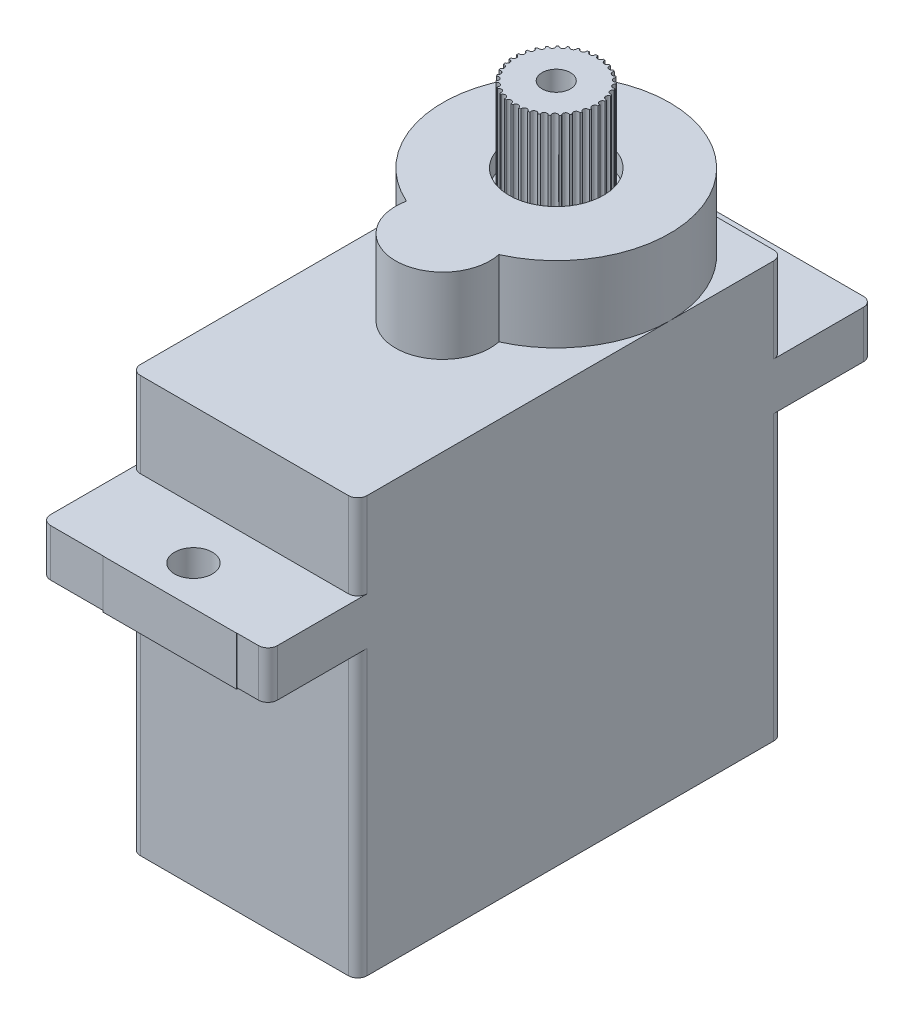
from build123d import *

# Parameters (mm, degrees)
Y_KSEKLIK_EKSTR_ZYON1_DEPTH  = 1
Y_KSEKLIK_EKSTR_ZYON2_DEPTH  = 5
IZIM3_W                      = 4
IZIM3_H                      = 1
KES_EKSTR_ZYON1_DEPTH        = 1
RADYUS1_R                    = 0.1
Y_KSEKLIK_EKSTR_ZYON4_DEPTH  = 9
Y_KSEKLIK_EKSTR_ZYON5_DEPTH  = 2.5
Y_KSEKLIK_EKSTR_ZYON6_DEPTH  = 3.5
Y_KSEKLIK_EKSTR_ZYON7_DEPTH  = 1
KES_EKSTR_ZYON2_DEPTH        = 1
Y_KSEKLIK_EKSTR_ZYON8_START  = 3
Y_KSEKLIK_EKSTR_ZYON8_DEPTH  = 3
RADYUS2_R                    = 0.5
Y_KSEKLIK_EKSTR_ZYON9_START  = 1
Y_KSEKLIK_EKSTR_ZYON9_DEPTH  = 1
IZIM11_R                     = 2.5
KES_EKSTR_ZYON3_DEPTH        = 10
IZIM15_R                     = 0.25
Y_KSEKLIK_EKSTR_ZYON12_DEPTH = 11
IZIM19_R                     = 2.25
Y_KSEKLIK_EKSTR_ZYON17_DEPTH = 5
IZIM20_R                     = 4.75
Y_KSEKLIK_EKSTR_ZYON18_DEPTH = 3
IZIM21_R                     = 0.75
KES_EKSTR_ZYON5_DEPTH        = 10
IZIM22_R                     = 0.5
Y_KSEKLIK_EKSTR_ZYON19_DEPTH = 5
IZIM23_R                     = 4
Y_KSEKLIK_EKSTR_ZYON20_DEPTH = 2
IZIM24_R                     = 0.75
Y_KSEKLIK_EKSTR_ZYON21_DEPTH = 7
IZIM25_R                     = 3.5
Y_KSEKLIK_EKSTR_ZYON22_DEPTH = 1
IZIM26_R                     = 4.5
Y_KSEKLIK_EKSTR_ZYON23_DEPTH = 1
KES_EKSTR_ZYON7_DEPTH        = 30
Y_KSEKLIK_EKSTR_ZYON33_DEPTH = 1
Y_KSEKLIK_EKSTR_ZYON34_DEPTH = 14
IZIM37_W                     = 8
IZIM37_H                     = 6
Y_KSEKLIK_EKSTR_ZYON36_DEPTH = 1
IZIM39_W                     = 4
IZIM39_H                     = 1
Y_KSEKLIK_EKSTR_ZYON37_DEPTH = 0.1
IZIM40_R                     = 0.4
Y_KSEKLIK_EKSTR_ZYON38_DEPTH = 2
IZIM41_R                     = 0.15
KES_EKSTR_ZYON8_DEPTH        = 5
SKETCH4_W                    = 7.062271717
SKETCH4_H                    = 4.39837951
BOSS_EXTRUDE6_DEPTH          = 2.57
SKETCH5_W                    = 6.419494601
SKETCH5_H                    = 4.235737176
BOSS_EXTRUDE7_DEPTH          = 2.57
SKETCH6_R                    = 1
CUT_EXTRUDE1_DEPTH           = 12.57


with BuildPart() as part:
    # Çizim1 → Yükseklik-Ekstrüzyon1 (new body)
    with BuildSketch(Plane(origin=(0, 0, 0), x_dir=(1, 0, 0), z_dir=(0, 1, 0))):
        with BuildLine():
            Line((-5.5, 11.25), (5.5, 11.25))
            ThreePointArc((5.5, 11.25), (5.853553391, 11.103553391), (6, 10.75))
            Line((6, 10.75), (6, -10.75))
            ThreePointArc((6, -10.75), (5.853553391, -11.103553391), (5.5, -11.25))
            Line((5.5, -11.25), (-5.5, -11.25))
            ThreePointArc((-5.5, -11.25), (-5.853553391, -11.103553391), (-6, -10.75))
            Line((-6, -10.75), (-6, 10.75))
            ThreePointArc((-6, 10.75), (-5.853553391, 11.103553391), (-5.5, 11.25))
        make_face()
    extrude(amount=Y_KSEKLIK_EKSTR_ZYON1_DEPTH)

    # Çizim2 → Yükseklik-Ekstrüzyon2 (add)
    with BuildSketch(Plane(origin=(0, 1, 0), x_dir=(1, 0, 0), z_dir=(0, 1, 0))):
        with BuildLine():
            Line((-5.5, 11.25), (5.5, 11.25))
            ThreePointArc((5.5, 11.25), (5.853553391, 11.103553391), (6, 10.75))
            Line((6, 10.75), (6, -10.75))
            ThreePointArc((6, -10.75), (5.853553391, -11.103553391), (5.5, -11.25))
            Line((5.5, -11.25), (-5.5, -11.25))
            ThreePointArc((-5.5, -11.25), (-5.853553391, -11.103553391), (-6, -10.75))
            Line((-6, -10.75), (-6, 10.75))
            ThreePointArc((-6, 10.75), (-5.853553391, 11.103553391), (-5.5, 11.25))
        make_face()
        with BuildLine():
            Line((-5, 9.25), (-5, -9.25))
            ThreePointArc((-5, -9.25), (-4.292893219, -9.542893219), (-4, -10.25))
            Line((-4, -10.25), (4, -10.25))
            ThreePointArc((4, -10.25), (4.292893219, -9.542893219), (5, -9.25))
            Line((5, -9.25), (5, 9.25))
            ThreePointArc((5, 9.25), (4.292893219, 9.542893219), (4, 10.25))
            Line((4, 10.25), (-4, 10.25))
            ThreePointArc((-4, 10.25), (-4.292893219, 9.542893219), (-5, 9.25))
        make_face(mode=Mode.SUBTRACT)
    extrude(amount=Y_KSEKLIK_EKSTR_ZYON2_DEPTH)

    # Çizim3 → Kes-Ekstrüzyon1 (cut)
    with BuildSketch(Plane(origin=(0, 6, 0), x_dir=(1, 0, 0), z_dir=(0, 1, 0))):
        with Locations((0, -10.75)):
            Rectangle(IZIM3_W, IZIM3_H)
    extrude(amount=-KES_EKSTR_ZYON1_DEPTH, mode=Mode.SUBTRACT)

    # Radyus1
    radyus1_edges = [part.edges().sort_by_distance(p)[0] for p in [
        (2, 5, 10.75),
        (-2, 5, 10.75),
    ]]
    fillet(radyus1_edges, radius=RADYUS1_R)

    # Çizim4 → Yükseklik-Ekstrüzyon4 (add)
    with BuildSketch(Plane(origin=(0, 6, 0), x_dir=(1, 0, 0), z_dir=(0, 1, 0))):
        with BuildLine():
            Line((5.5, 11.25), (-5.5, 11.25))
            ThreePointArc((-5.5, 11.25), (-5.853553391, 11.103553391), (-6, 10.75))
            Line((-6, 10.75), (-6, -10.75))
            ThreePointArc((-6, -10.75), (-5.853553391, -11.103553391), (-5.5, -11.25))
            Line((-5.5, -11.25), (-2, -11.25))
            Line((-2, -11.25), (2, -11.25))
            Line((2, -11.25), (5.5, -11.25))
            ThreePointArc((5.5, -11.25), (5.853553391, -11.103553391), (6, -10.75))
            Line((6, -10.75), (6, 10.75))
            ThreePointArc((6, 10.75), (5.853553391, 11.103553391), (5.5, 11.25))
        make_face()
        with BuildLine():
            ThreePointArc((-5, 9.25), (-4.292893219, 9.542893219), (-4, 10.25))
            Line((-4, 10.25), (4, 10.25))
            ThreePointArc((4, 10.25), (4.292893219, 9.542893219), (5, 9.25))
            Line((5, 9.25), (5, -9.25))
            ThreePointArc((5, -9.25), (4.292893219, -9.542893219), (4, -10.25))
            Line((4, -10.25), (2, -10.25))
            Line((2, -10.25), (-2, -10.25))
            Line((-2, -10.25), (-4, -10.25))
            ThreePointArc((-4, -10.25), (-4.292893219, -9.542893219), (-5, -9.25))
            Line((-5, -9.25), (-5, 9.25))
        make_face(mode=Mode.SUBTRACT)
    extrude(amount=Y_KSEKLIK_EKSTR_ZYON4_DEPTH)

    # Çizim6 → Yükseklik-Ekstrüzyon5 (add)
    with BuildSketch(Plane(origin=(0, 15, 0), x_dir=(1, 0, 0), z_dir=(0, 1, 0))):
        with BuildLine():
            Line((-5.5, 16), (-0.7, 16))
            ThreePointArc((-0.7, 16), (-0.558578644, 15.941421356), (-0.5, 15.8))
            Line((-0.5, 15.8), (-0.5, 14.224679434))
            ThreePointArc((-0.5, 14.224679434), (-0.522048696, 14.133392342), (-0.583333333, 14.062232862))
            ThreePointArc((-0.583333333, 14.062232862), (0, 12.25), (0.583333333, 14.062232862))
            ThreePointArc((0.583333333, 14.062232862), (0.522048696, 14.133392342), (0.5, 14.224679434))
            Line((0.5, 14.224679434), (0.5, 15.8))
            ThreePointArc((0.5, 15.8), (0.558578644, 15.941421356), (0.7, 16))
            Line((0.7, 16), (5.5, 16))
            ThreePointArc((5.5, 16), (5.853553391, 15.853553391), (6, 15.5))
            Line((6, 15.5), (6, -15.5))
            ThreePointArc((6, -15.5), (5.853553391, -15.853553391), (5.5, -16))
            Line((5.5, -16), (0.7, -16))
            ThreePointArc((0.7, -16), (0.558578644, -15.941421356), (0.5, -15.8))
            Line((0.5, -15.8), (0.5, -14.224679434))
            ThreePointArc((0.5, -14.224679434), (0.522048696, -14.133392342), (0.583333333, -14.062232862))
            ThreePointArc((0.583333333, -14.062232862), (0, -12.25), (-0.583333333, -14.062232862))
            ThreePointArc((-0.583333333, -14.062232862), (-0.522048696, -14.133392342), (-0.5, -14.224679434))
            Line((-0.5, -14.224679434), (-0.5, -15.8))
            ThreePointArc((-0.5, -15.8), (-0.558578644, -15.941421356), (-0.7, -16))
            Line((-0.7, -16), (-5.5, -16))
            ThreePointArc((-5.5, -16), (-5.853553391, -15.853553391), (-6, -15.5))
            Line((-6, -15.5), (-6, 15.5))
            ThreePointArc((-6, 15.5), (-5.853553391, 15.853553391), (-5.5, 16))
        make_face()
        with BuildLine():
            Line((-4, 10.25), (4, 10.25))
            ThreePointArc((4, 10.25), (4.292893219, 9.542893219), (5, 9.25))
            Line((5, 9.25), (5, -9.25))
            ThreePointArc((5, -9.25), (4.292893219, -9.542893219), (4, -10.25))
            Line((4, -10.25), (-4, -10.25))
            ThreePointArc((-4, -10.25), (-4.292893219, -9.542893219), (-5, -9.25))
            Line((-5, -9.25), (-5, 9.25))
            ThreePointArc((-5, 9.25), (-4.292893219, 9.542893219), (-4, 10.25))
        make_face(mode=Mode.SUBTRACT)
    extrude(amount=Y_KSEKLIK_EKSTR_ZYON5_DEPTH)

    # Çizim7 → Yükseklik-Ekstrüzyon6 (add)
    with BuildSketch(Plane(origin=(0, 17.5, 0), x_dir=(1, 0, 0), z_dir=(0, 1, 0))):
        with BuildLine():
            Line((5.5, 11.25), (-5.5, 11.25))
            ThreePointArc((-5.5, 11.25), (-5.853553391, 11.103553391), (-6, 10.75))
            Line((-6, 10.75), (-6, -10.75))
            ThreePointArc((-6, -10.75), (-5.853553391, -11.103553391), (-5.5, -11.25))
            Line((-5.5, -11.25), (5.5, -11.25))
            ThreePointArc((5.5, -11.25), (5.853553391, -11.103553391), (6, -10.75))
            Line((6, -10.75), (6, 10.75))
            ThreePointArc((6, 10.75), (5.853553391, 11.103553391), (5.5, 11.25))
        make_face()
        with BuildLine():
            Line((-5, -9.25), (-5, 9.25))
            ThreePointArc((-5, 9.25), (-4.292893219, 9.542893219), (-4, 10.25))
            Line((-4, 10.25), (4, 10.25))
            ThreePointArc((4, 10.25), (4.292893219, 9.542893219), (5, 9.25))
            Line((5, 9.25), (5, -9.25))
            ThreePointArc((5, -9.25), (4.292893219, -9.542893219), (4, -10.25))
            Line((4, -10.25), (-4, -10.25))
            ThreePointArc((-4, -10.25), (-4.292893219, -9.542893219), (-5, -9.25))
        make_face(mode=Mode.SUBTRACT)
    extrude(amount=Y_KSEKLIK_EKSTR_ZYON6_DEPTH)

    # Çizim8 → Yükseklik-Ekstrüzyon7 (add)
    with BuildSketch(Plane(origin=(0, 21, 0), x_dir=(1, 0, 0), z_dir=(0, 1, 0))):
        with BuildLine():
            Line((-5.5, 11.25), (5.5, 11.25))
            ThreePointArc((5.5, 11.25), (5.853553391, 11.103553391), (6, 10.75))
            Line((6, 10.75), (6, -10.75))
            ThreePointArc((6, -10.75), (5.853553391, -11.103553391), (5.5, -11.25))
            Line((5.5, -11.25), (-5.5, -11.25))
            ThreePointArc((-5.5, -11.25), (-5.853553391, -11.103553391), (-6, -10.75))
            Line((-6, -10.75), (-6, 10.75))
            ThreePointArc((-6, 10.75), (-5.853553391, 11.103553391), (-5.5, 11.25))
        make_face()
    extrude(amount=Y_KSEKLIK_EKSTR_ZYON7_DEPTH)

    # Çizim9 → Kes-Ekstrüzyon2 (cut)
    with BuildSketch(Plane(origin=(0, 22, 0), x_dir=(1, 0, 0), z_dir=(0, 1, 0))):
        with BuildLine():
            ThreePointArc((1.015291078, 0.354166667), (0, 10.25), (-1.015291078, 0.354166667))
            ThreePointArc((-1.015291078, 0.354166667), (0, -2.25), (1.015291078, 0.354166667))
        make_face()
    extrude(amount=-KES_EKSTR_ZYON2_DEPTH, mode=Mode.SUBTRACT)

    # Çizim9<3> → Yükseklik-Ekstrüzyon8 (add)
    with BuildSketch(Plane(origin=(0, 22, 0), x_dir=(1, 0, 0), z_dir=(0, 1, 0)).offset(Y_KSEKLIK_EKSTR_ZYON8_START)):
        with BuildLine():
            ThreePointArc((2.445144707, -0.229166667), (0, 11.25), (-2.445144707, -0.229166667))
            ThreePointArc((-2.445144707, -0.229166667), (0, -3.25), (2.445144707, -0.229166667))
        make_face()
        with BuildLine():
            ThreePointArc((1.015291078, 0.354166667), (0, 10.25), (-1.015291078, 0.354166667))
            ThreePointArc((-1.015291078, 0.354166667), (0, -2.25), (1.015291078, 0.354166667))
        make_face(mode=Mode.SUBTRACT)
    extrude(amount=-Y_KSEKLIK_EKSTR_ZYON8_DEPTH)

    # Radyus2
    radyus2_edges = [part.edges().sort_by_distance(p)[0] for p in [
        (1.015291078, 23, -0.354166667),
        (-1.015291078, 23, -0.354166667),
    ]]
    fillet(radyus2_edges, radius=RADYUS2_R)

    # Çizim10 → Yükseklik-Ekstrüzyon9 (add)
    with BuildSketch(Plane(origin=(0, 25, 0), x_dir=(1, 0, 0), z_dir=(0, 1, 0)).offset(Y_KSEKLIK_EKSTR_ZYON9_START)):
        with BuildLine():
            ThreePointArc((2.445144707, -0.229166667), (0, 11.25), (-2.445144707, -0.229166667))
            ThreePointArc((-2.445144707, -0.229166667), (0, -3.25), (2.445144707, -0.229166667))
        make_face()
    extrude(amount=-Y_KSEKLIK_EKSTR_ZYON9_DEPTH)

    # Çizim11 → Kes-Ekstrüzyon3 (cut)
    with BuildSketch(Plane(origin=(0, 26, 0), x_dir=(1, 0, 0), z_dir=(0, 1, 0))):
        with Locations((0, 5.25)):
            Circle(IZIM11_R)
    extrude(amount=-KES_EKSTR_ZYON3_DEPTH, mode=Mode.SUBTRACT)

    # Çizim15 → Yükseklik-Ekstrüzyon12 (add)
    with BuildSketch(Plane(origin=(0, 26, 0), x_dir=(1, 0, 0), z_dir=(0, 1, 0))):
        with Locations((0, -0.75)):
            Circle(IZIM15_R)
    extrude(amount=-Y_KSEKLIK_EKSTR_ZYON12_DEPTH)



with BuildPart() as body_2:
    # Çizim19 → Yükseklik-Ekstrüzyon17 (new body)
    with BuildSketch(Plane(origin=(0, 30, 0), x_dir=(1, 0, 0), z_dir=(0, 1, 0))):
        with Locations((0, 5.25)):
            Circle(IZIM19_R)
    extrude(amount=-Y_KSEKLIK_EKSTR_ZYON17_DEPTH)


with BuildPart() as part_1:
    add(part.part)

    add(body_2.part)  # Yükseklik-Ekstrüzyon18 merges body 2
    # Çizim20 → Yükseklik-Ekstrüzyon18 (add)
    with BuildSketch(Plane.XZ.offset(-25)):
        with Locations((0, -5.25)):
            Circle(IZIM20_R)
    extrude(amount=Y_KSEKLIK_EKSTR_ZYON18_DEPTH)

    # Çizim21 → Kes-Ekstrüzyon5 (cut)
    with BuildSketch(Plane(origin=(0, 30, 0), x_dir=(1, 0, 0), z_dir=(0, 1, 0))):
        with Locations((0, 5.25)):
            Circle(IZIM21_R)
    extrude(amount=-KES_EKSTR_ZYON5_DEPTH, mode=Mode.SUBTRACT)

    # Çizim22 → Yükseklik-Ekstrüzyon19 (add)
    with BuildSketch(Plane(origin=(0, 25.5, 0), x_dir=(1, 0, 0), z_dir=(0, 1, 0))):
        with Locations((0, -0.75)):
            Circle(IZIM22_R)
    extrude(amount=-Y_KSEKLIK_EKSTR_ZYON19_DEPTH)

    # Çizim23 → Yükseklik-Ekstrüzyon20 (add)
    with BuildSketch(Plane.XZ.offset(-20.5)):
        with Locations((0, 0.75)):
            Circle(IZIM23_R)
    extrude(amount=Y_KSEKLIK_EKSTR_ZYON20_DEPTH)

    # Çizim26 → Yükseklik-Ekstrüzyon23 (add)
    with BuildSketch(Plane(origin=(0, 17.5, 0), x_dir=(-1, 0, 0), z_dir=(0, -1, 0))):
        with Locations((0, -0.75)):
            Circle(IZIM26_R)
    extrude(amount=Y_KSEKLIK_EKSTR_ZYON23_DEPTH)

    # Çizim32 → Kes-Ekstrüzyon7 (cut)
    with BuildSketch(Plane(origin=(0, 0, 10.25), x_dir=(-1, 0, 0), z_dir=(0, 0, -1))):
        with BuildLine():
            Line((2, 6), (-2, 6))
            Line((-2, 6), (-2, 5.1))
            ThreePointArc((-2, 5.1), (-1.970710678, 5.029289322), (-1.9, 5))
            Line((-1.9, 5), (1.9, 5))
            ThreePointArc((1.9, 5), (1.970710678, 5.029289322), (2, 5.1))
            Line((2, 5.1), (2, 6))
        make_face()
    extrude(amount=KES_EKSTR_ZYON7_DEPTH, mode=Mode.SUBTRACT)

    # Çizim33 → Yükseklik-Ekstrüzyon33 (add)
    with BuildSketch(Plane.XY.offset(11.25)):
        with BuildLine():
            Line((-2, 6), (2, 6))
            Line((2, 6), (2, 5.1))
            ThreePointArc((2, 5.1), (1.970710678, 5.029289322), (1.9, 5))
            Line((1.9, 5), (-1.9, 5))
            ThreePointArc((-1.9, 5), (-1.970710678, 5.029289322), (-2, 5.1))
            Line((-2, 5.1), (-2, 6))
        make_face()
    extrude(amount=-Y_KSEKLIK_EKSTR_ZYON33_DEPTH)

    # Çizim34 → Yükseklik-Ekstrüzyon34 (add)
    with BuildSketch(Plane(origin=(0, 1, 0), x_dir=(1, 0, 0), z_dir=(0, 1, 0))):
        with BuildLine():
            Line((-3, -3.25), (3, -3.25))
            ThreePointArc((3, -3.25), (3.707106781, -3.542893219), (4, -4.25))
            Line((4, -4.25), (4, -8.25))
            ThreePointArc((4, -8.25), (3.707106781, -8.957106781), (3, -9.25))
            Line((3, -9.25), (-3, -9.25))
            ThreePointArc((-3, -9.25), (-3.707106781, -8.957106781), (-4, -8.25))
            Line((-4, -8.25), (-4, -4.25))
            ThreePointArc((-4, -4.25), (-3.707106781, -3.542893219), (-3, -3.25))
        make_face()
    extrude(amount=Y_KSEKLIK_EKSTR_ZYON34_DEPTH)

    # Çizim37 → Yükseklik-Ekstrüzyon36 (add)
    with BuildSketch(Plane(origin=(0, 1, 0), x_dir=(-1, 0, 0), z_dir=(0, -1, 0))):
        with Locations((0, -6.25)):
            Rectangle(IZIM37_W, IZIM37_H)
    extrude(amount=-Y_KSEKLIK_EKSTR_ZYON36_DEPTH)

    # Çizim39 → Yükseklik-Ekstrüzyon37 (add)
    with BuildSketch(Plane(origin=(0, 0, -10.75), x_dir=(-1, 0, 0), z_dir=(0, 0, -1))):
        with Locations((0, 5.514566781)):
            Rectangle(IZIM39_W, IZIM39_H)
    extrude(amount=Y_KSEKLIK_EKSTR_ZYON37_DEPTH)

    # Çizim40 → Yükseklik-Ekstrüzyon38 (add)
    with BuildSketch(Plane(origin=(0, 0, -10.85), x_dir=(-1, 0, 0), z_dir=(0, 0, -1))):
        with Locations((0, 5.55)):
            Circle(IZIM40_R)
        with Locations((1, 5.55)):
            Circle(IZIM40_R)
        with Locations((-1, 5.55)):
            Circle(IZIM40_R)
    extrude(amount=Y_KSEKLIK_EKSTR_ZYON38_DEPTH)

    # Çizim41 → Kes-Ekstrüzyon8 (cut)
    with BuildSketch(Plane(origin=(0, 30, 0), x_dir=(1, 0, 0), z_dir=(0, 1, 0))):
        with Locations((-2.25, 5.25)):
            Circle(IZIM41_R)
        with Locations((-2.213841574, 5.651753013)):
            Circle(IZIM41_R)
        with Locations((-2.213841574, 4.848246987)):
            Circle(IZIM41_R)
        with Locations((-2.106528459, 6.040593354)):
            Circle(IZIM41_R)
        with Locations((-2.106528459, 4.459406646)):
            Circle(IZIM41_R)
        with Locations((-1.931509786, 6.404023374)):
            Circle(IZIM41_R)
        with Locations((-1.931509786, 4.095976626)):
            Circle(IZIM41_R)
        with Locations((-1.694410799, 6.730362133)):
            Circle(IZIM41_R)
        with Locations((-1.694410799, 3.769637867)):
            Circle(IZIM41_R)
        with Locations((-1.402852054, 7.009120836)):
            Circle(IZIM41_R)
        with Locations((-1.402852054, 3.490879164)):
            Circle(IZIM41_R)
        with Locations((-1.066204491, 7.231339947)):
            Circle(IZIM41_R)
        with Locations((-1.066204491, 3.268660053)):
            Circle(IZIM41_R)
        with Locations((-0.695288237, 7.389877162)):
            Circle(IZIM41_R)
        with Locations((-0.695288237, 3.110122838)):
            Circle(IZIM41_R)
        with Locations((-0.302024848, 7.479636964)):
            Circle(IZIM41_R)
        with Locations((-0.302024848, 3.020363036)):
            Circle(IZIM41_R)
        with Locations((0.100945868, 7.4977344)):
            Circle(IZIM41_R)
        with Locations((0.100945868, 3.0022656)):
            Circle(IZIM41_R)
        with Locations((0.500672101, 7.443587802)):
            Circle(IZIM41_R)
        with Locations((0.500672101, 3.056412198)):
            Circle(IZIM41_R)
        with Locations((0.884306321, 7.318937488)):
            Circle(IZIM41_R)
        with Locations((0.884306321, 3.181062512)):
            Circle(IZIM41_R)
        with Locations((1.239518208, 7.127789821)):
            Circle(IZIM41_R)
        with Locations((1.239518208, 3.372210179)):
            Circle(IZIM41_R)
        with Locations((1.55489096, 6.876288444)):
            Circle(IZIM41_R)
        with Locations((1.55489096, 3.623711556)):
            Circle(IZIM41_R)
        with Locations((1.820288237, 6.572516818)):
            Circle(IZIM41_R)
        with Locations((1.820288237, 3.927483182)):
            Circle(IZIM41_R)
        with Locations((2.027179953, 6.226238413)):
            Circle(IZIM41_R)
        with Locations((2.027179953, 4.273761587)):
            Circle(IZIM41_R)
        with Locations((2.168916437, 5.848582903)):
            Circle(IZIM41_R)
        with Locations((2.168916437, 4.651417097)):
            Circle(IZIM41_R)
        with Locations((2.240942161, 5.451688445)):
            Circle(IZIM41_R)
        with Locations((2.240942161, 5.048311555)):
            Circle(IZIM41_R)
    extrude(amount=-KES_EKSTR_ZYON8_DEPTH, mode=Mode.SUBTRACT)

    # Sketch4 → Boss-Extrude6 (add)
    with BuildSketch(Plane(origin=(0, 17.5, 0), x_dir=(1, 0, 0), z_dir=(0, 1, 0))):
        with Locations((0.821734952, -13.810892321)):
            Rectangle(SKETCH4_W, SKETCH4_H)
    extrude(amount=-BOSS_EXTRUDE6_DEPTH)

    # Sketch5 → Boss-Extrude7 (add)
    with BuildSketch(Plane(origin=(0, 17.5, 0), x_dir=(1, 0, 0), z_dir=(0, 1, 0))):
        with Locations((0.67291463, 13.882131412)):
            Rectangle(SKETCH5_W, SKETCH5_H)
    extrude(amount=-BOSS_EXTRUDE7_DEPTH)

    # Sketch6 → Cut-Extrude1 (cut)
    with BuildSketch(Plane(origin=(0, 17.5, 0), x_dir=(1, 0, 0), z_dir=(0, 1, 0))):
        with Locations((0, -13.94)):
            Circle(SKETCH6_R)
        with Locations((0, 13.94)):
            Circle(SKETCH6_R)
    extrude(amount=-CUT_EXTRUDE1_DEPTH, mode=Mode.SUBTRACT)


with BuildPart() as body_2_2:
    # Çizim24 → Yükseklik-Ekstrüzyon21 (new body)
    with BuildSketch(Plane.XZ.offset(-22)):
        with Locations((0, -5.25)):
            Circle(IZIM24_R)
    extrude(amount=Y_KSEKLIK_EKSTR_ZYON21_DEPTH)

    # Çizim25 → Yükseklik-Ekstrüzyon22 (add)
    with BuildSketch(Plane(origin=(0, 19, 0), x_dir=(-1, 0, 0), z_dir=(0, -1, 0))):
        with Locations((0, 5.25)):
            Circle(IZIM25_R)
    extrude(amount=Y_KSEKLIK_EKSTR_ZYON22_DEPTH)


solid = Compound([part_1.part, body_2_2.part])
